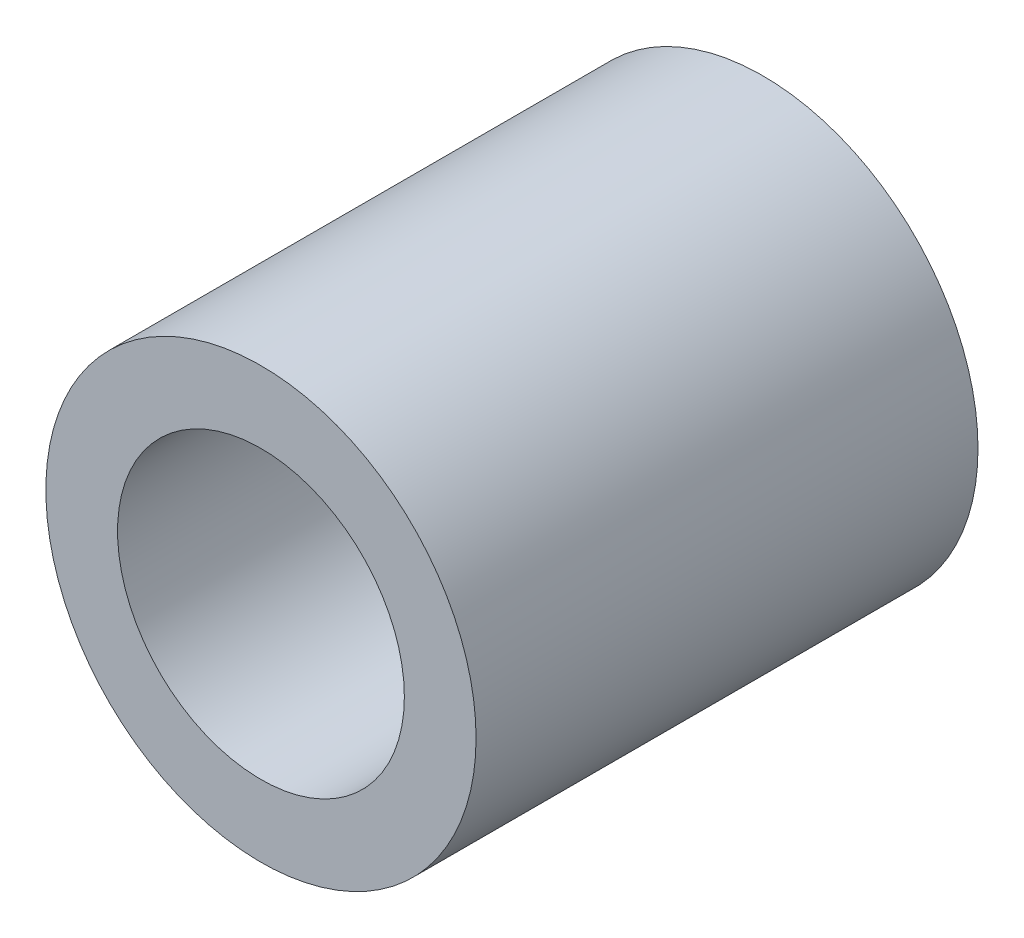
from build123d import *

# Parameters (mm, degrees)
ESQUISSE1_R        = 1.5
ESQUISSE1_R_2      = 1
BOSS_EXTRU_1_DEPTH = 3.5


with BuildPart() as part:
    # Esquisse1 → Boss.-Extru.1 (new body)
    with BuildSketch(Plane.XY):
        Circle(ESQUISSE1_R)
        Circle(ESQUISSE1_R_2, mode=Mode.SUBTRACT)
    extrude(amount=BOSS_EXTRU_1_DEPTH)


solid = part.part
